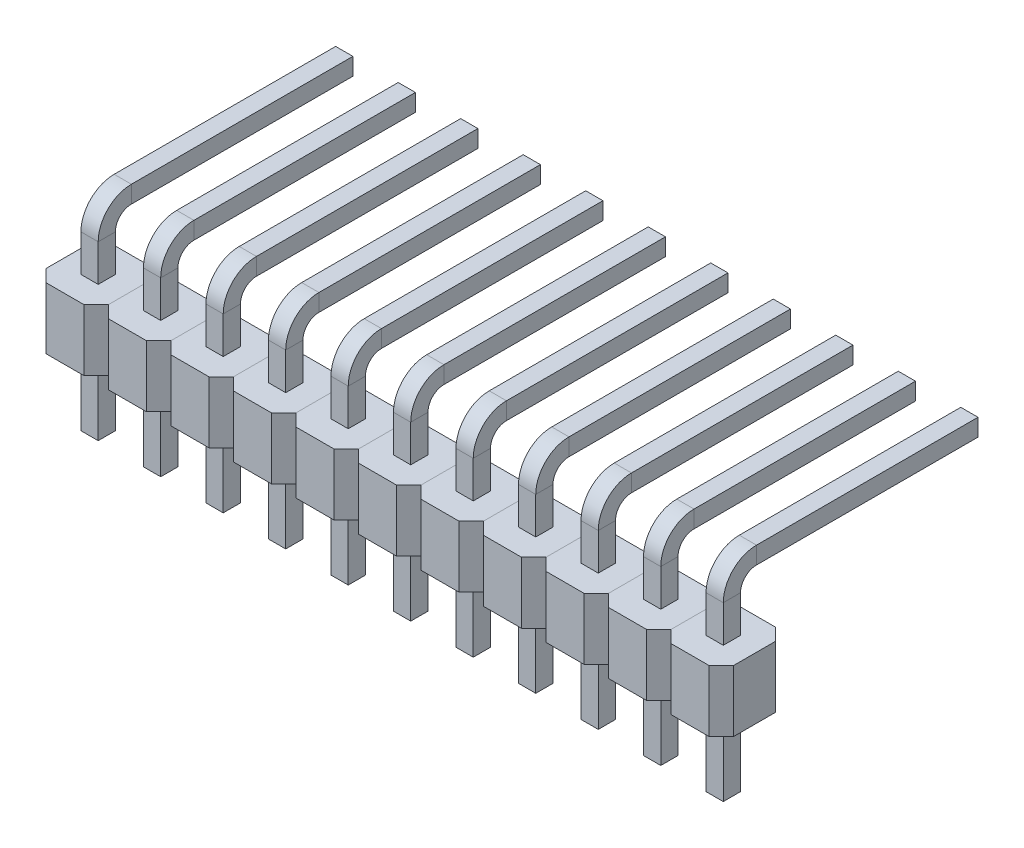
from build123d import *

# Parameters (mm, degrees)
SKETCH1_W           = 0.7
SKETCH1_H           = 0.7
SKETCH1_55_W        = 2.54
SKETCH1_55_H        = 2.7
BOSS_EXTRUDE1_DEPTH = 2.5
CHAMFER1_SIZE       = 0.5
LPATTERN1_COUNT     = 11
LPATTERN1_PITCH     = 2.54


with BuildPart() as part:
    # Sweep3: sweep along a path in Sketch2
    with BuildLine(Plane(origin=(1.25, 0, 0), x_dir=(0, 0, -1), z_dir=(1, 0, 0))) as sweep3_path:
        Line((-1.35, -3), (-1.35, 4))
        ThreePointArc((-1.35, 4), (-1.057106781, 4.707106781), (-0.35, 5))
        Line((-0.35, 5), (8.65, 5))
    # Sketch1 → Sweep3 (sweep)
    with BuildSketch(Plane(origin=(0, 0, 0), x_dir=(1, 0, 0), z_dir=(0, 1, 0))):
        with Locations((1.27, -1.35)):
            Rectangle(SKETCH1_W, SKETCH1_H)
    sweep(path=sweep3_path.line)


with BuildPart() as body_2:
    # Sketch1_55 → Boss-Extrude1 (new body)
    with BuildSketch(Plane(origin=(0, 0, 0), x_dir=(1, 0, 0), z_dir=(0, 1, 0))):
        with Locations((1.27, -1.35)):
            Rectangle(SKETCH1_55_W, SKETCH1_55_H)
    extrude(amount=BOSS_EXTRUDE1_DEPTH)

    # Chamfer1
    chamfer1_edges = [body_2.edges().sort_by_distance(p)[0] for p in [
        (0, 1.25, 2.7),
        (2.54, 1.25, 2.7),
        (0, 1.25, 0),
        (2.54, 1.25, 0),
    ]]
    chamfer(chamfer1_edges, length=CHAMFER1_SIZE)


with BuildPart() as lpattern1_1:
    # LPattern1: pattern copy
    add(body_2.part.moved(Location(Vector(-1, 0, 0) * (1 * LPATTERN1_PITCH))))


with BuildPart() as lpattern1_2:
    # LPattern1: pattern copy
    add(body_2.part.moved(Location(Vector(-1, 0, 0) * (2 * LPATTERN1_PITCH))))


with BuildPart() as lpattern1_3:
    # LPattern1: pattern copy
    add(body_2.part.moved(Location(Vector(-1, 0, 0) * (3 * LPATTERN1_PITCH))))


with BuildPart() as lpattern1_4:
    # LPattern1: pattern copy
    add(body_2.part.moved(Location(Vector(-1, 0, 0) * (4 * LPATTERN1_PITCH))))


with BuildPart() as lpattern1_5:
    # LPattern1: pattern copy
    add(body_2.part.moved(Location(Vector(-1, 0, 0) * (5 * LPATTERN1_PITCH))))


with BuildPart() as lpattern1_6:
    # LPattern1: pattern copy
    add(body_2.part.moved(Location(Vector(-1, 0, 0) * (6 * LPATTERN1_PITCH))))


with BuildPart() as lpattern1_7:
    # LPattern1: pattern copy
    add(body_2.part.moved(Location(Vector(-1, 0, 0) * (7 * LPATTERN1_PITCH))))


with BuildPart() as lpattern1_8:
    # LPattern1: pattern copy
    add(body_2.part.moved(Location(Vector(-1, 0, 0) * (8 * LPATTERN1_PITCH))))


with BuildPart() as lpattern1_9:
    # LPattern1: pattern copy
    add(body_2.part.moved(Location(Vector(-1, 0, 0) * (9 * LPATTERN1_PITCH))))


with BuildPart() as lpattern1_10:
    # LPattern1: pattern copy
    add(body_2.part.moved(Location(Vector(-1, 0, 0) * (10 * LPATTERN1_PITCH))))


with BuildPart() as lpattern1_11:
    # LPattern1: pattern copy
    add(part.part.moved(Location(Vector(-1, 0, 0) * (1 * LPATTERN1_PITCH))))


with BuildPart() as lpattern1_12:
    # LPattern1: pattern copy
    add(part.part.moved(Location(Vector(-1, 0, 0) * (2 * LPATTERN1_PITCH))))


with BuildPart() as lpattern1_13:
    # LPattern1: pattern copy
    add(part.part.moved(Location(Vector(-1, 0, 0) * (3 * LPATTERN1_PITCH))))


with BuildPart() as lpattern1_14:
    # LPattern1: pattern copy
    add(part.part.moved(Location(Vector(-1, 0, 0) * (4 * LPATTERN1_PITCH))))


with BuildPart() as lpattern1_15:
    # LPattern1: pattern copy
    add(part.part.moved(Location(Vector(-1, 0, 0) * (5 * LPATTERN1_PITCH))))


with BuildPart() as lpattern1_16:
    # LPattern1: pattern copy
    add(part.part.moved(Location(Vector(-1, 0, 0) * (6 * LPATTERN1_PITCH))))


with BuildPart() as lpattern1_17:
    # LPattern1: pattern copy
    add(part.part.moved(Location(Vector(-1, 0, 0) * (7 * LPATTERN1_PITCH))))


with BuildPart() as lpattern1_18:
    # LPattern1: pattern copy
    add(part.part.moved(Location(Vector(-1, 0, 0) * (8 * LPATTERN1_PITCH))))


with BuildPart() as lpattern1_19:
    # LPattern1: pattern copy
    add(part.part.moved(Location(Vector(-1, 0, 0) * (9 * LPATTERN1_PITCH))))


with BuildPart() as lpattern1_20:
    # LPattern1: pattern copy
    add(part.part.moved(Location(Vector(-1, 0, 0) * (10 * LPATTERN1_PITCH))))


solid = Compound([part.part, body_2.part, lpattern1_1.part, lpattern1_2.part, lpattern1_3.part, lpattern1_4.part, lpattern1_5.part, lpattern1_6.part, lpattern1_7.part, lpattern1_8.part, lpattern1_9.part, lpattern1_10.part, lpattern1_11.part, lpattern1_12.part, lpattern1_13.part, lpattern1_14.part, lpattern1_15.part, lpattern1_16.part, lpattern1_17.part, lpattern1_18.part, lpattern1_19.part, lpattern1_20.part])
